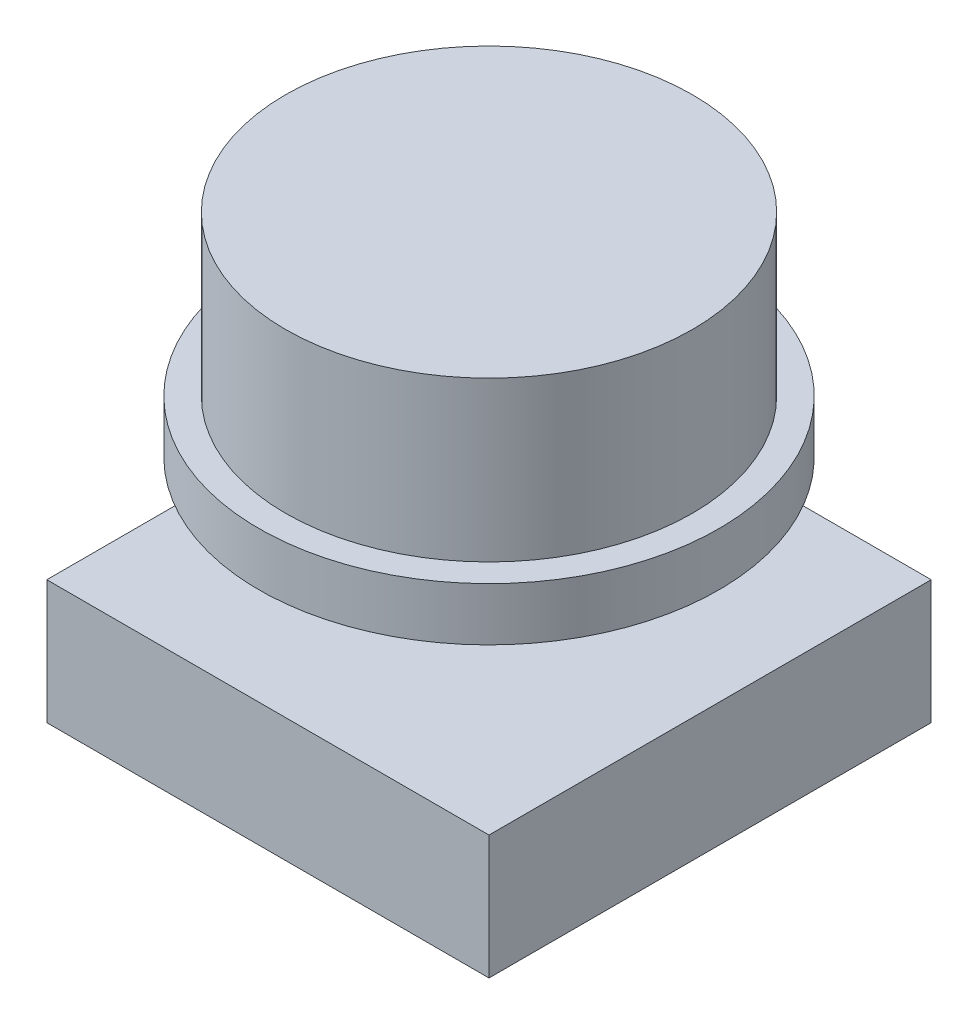
from build123d import *

# Parameters (mm, degrees)
SKETCH_1_R      = 5.75
EXTRUDE_1_DEPTH = 6
SKETCH_2_R      = 6.5
EXTRUDE_2_DEPTH = 1.5
EXTRUDE_START   = -6
SKETCH_3_W      = 3
SKETCH_3_H      = 3
EXTRUDE_3_DEPTH = 12.5
SKETCH_4_W      = 12.5
SKETCH_4_H      = 12.5
EXTRUDE_4_DEPTH = 3.5


with BuildPart() as part:
    # Эскиз1 → Бобышка-Вытянуть1 (new body)
    with BuildSketch(Plane(origin=(0, 0, 0), x_dir=(1, 0, 0), z_dir=(0, 1, 0))):
        Circle(SKETCH_1_R)
    extrude(amount=EXTRUDE_1_DEPTH)

    # Эскиз2 → Бобышка-Вытянуть2 (add)
    with BuildSketch(Plane.XZ):
        Circle(SKETCH_2_R)
    extrude(amount=-EXTRUDE_2_DEPTH)

    # Эскиз3 → Бобышка-Вытянуть3 (add)
    with BuildSketch(Plane.XZ.offset(EXTRUDE_START)):
        Rectangle(SKETCH_3_W, SKETCH_3_H)
    extrude(amount=EXTRUDE_3_DEPTH)

    # Эскиз4 → Бобышка-Вытянуть4 (add)
    with BuildSketch(Plane.XZ.offset(6.5)):
        Rectangle(SKETCH_4_W, SKETCH_4_H)
    extrude(amount=-EXTRUDE_4_DEPTH)


solid = part.part
